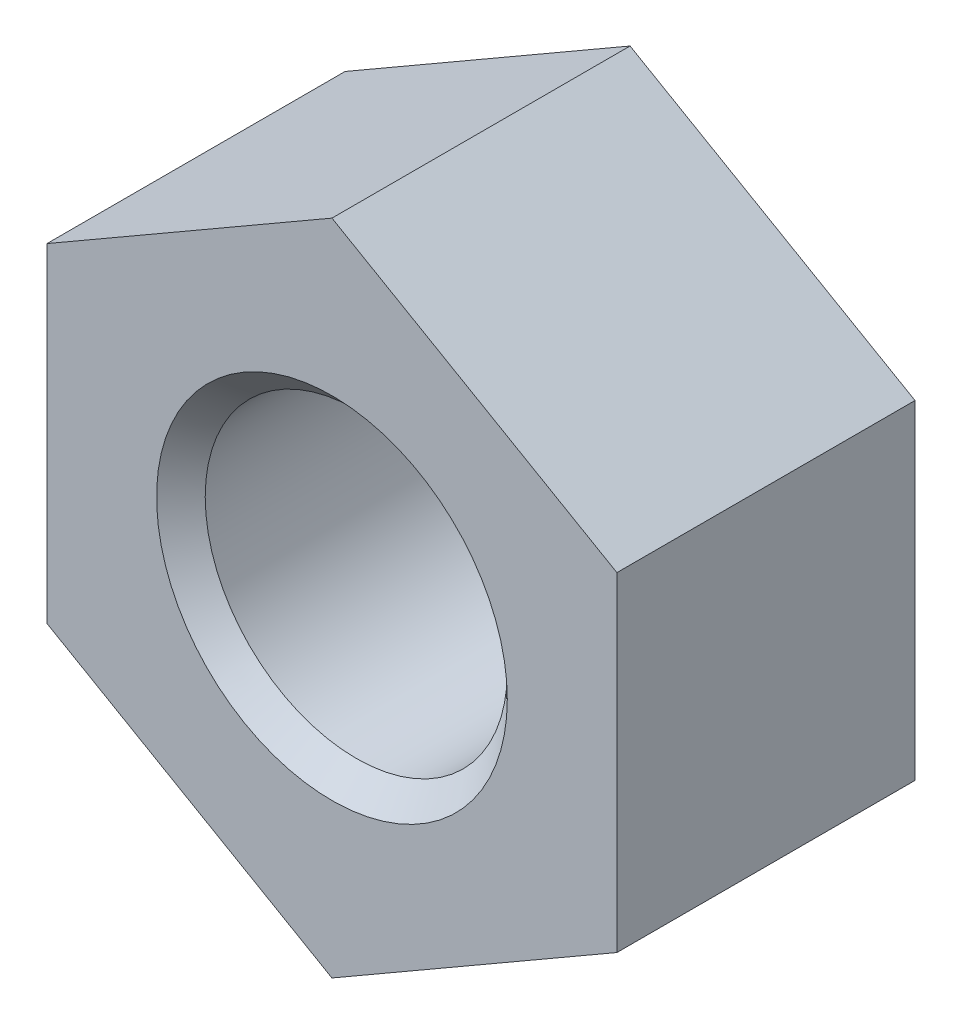
from build123d import *

# Parameters (mm, degrees)
SKETCH_1_R      = 3.4455
EXTRUDE_1_DEPTH = 6.8
CHAMFER_1_SIZE  = 0.5545


with BuildPart() as part:
    # Эскиз1 → Бобышка-Вытянуть1 (new body)
    with BuildSketch(Plane.XY):
        Polygon((0, 7.505553499), (-6.5, 3.75277675), (-6.5, -3.75277675), (0, -7.505553499), (6.5, -3.75277675), (6.5, 3.75277675), align=None)
        Circle(SKETCH_1_R, mode=Mode.SUBTRACT)
    extrude(amount=EXTRUDE_1_DEPTH)

    # Фаска1
    chamfer_1_edges = [part.edges().sort_by_distance(p)[0] for p in [
        (-3.4455, 0, 0),
        (-3.4455, 0, 6.8),
    ]]
    chamfer(chamfer_1_edges, length=CHAMFER_1_SIZE)


solid = part.part
